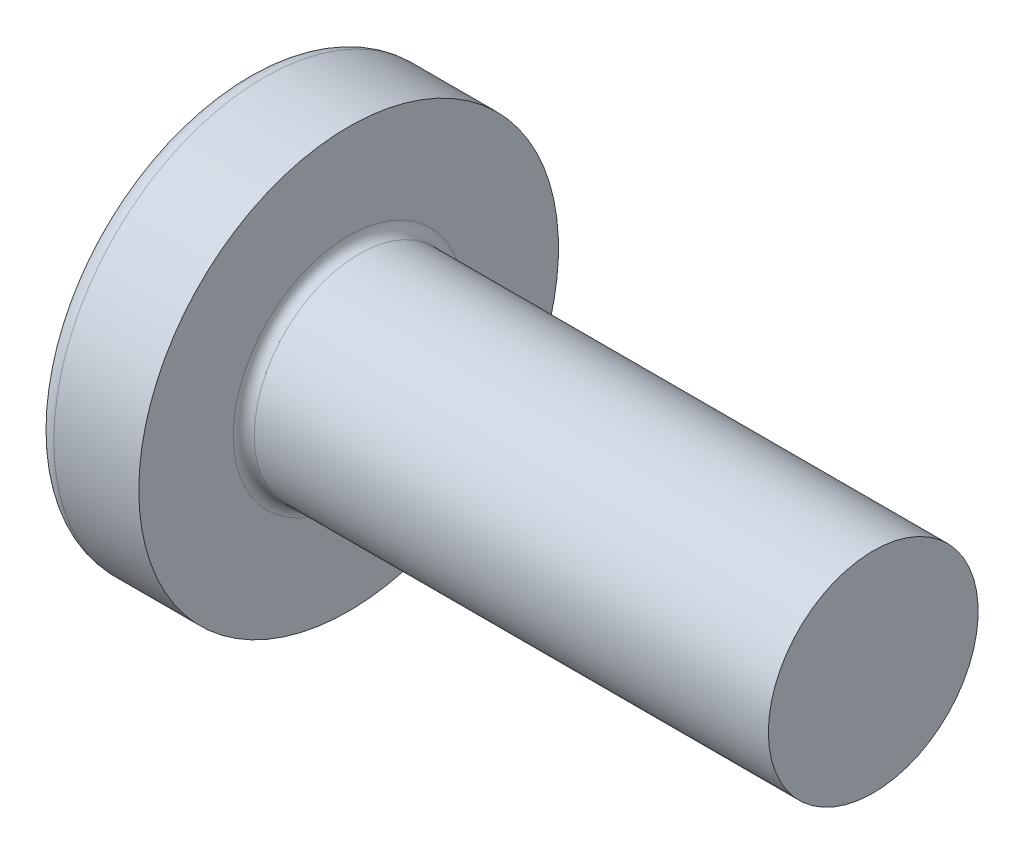
from build123d import *

# Parameters (mm, degrees)
FILLET1_R    = 0.1
SKETCH3_W    = 0.48
SKETCH3_H    = 2.1
SKETCH4_W    = 0.48
SKETCH4_H    = 0.68402847
RECPAT_COUNT = 2
RECPAT_ANGLE = 90


with BuildPart() as part:
    # BodySke → Base-Revolve (revolve)
    with BuildSketch(Plane.XY):
        with BuildLine():
            Line((1.6, 1), (1.6, 2))
            Line((1.6, 2), (0.790020747, 2))
            ThreePointArc((0.790020747, 2), (0.709789294, 1.981130115), (0.646379599, 1.928476821))
            ThreePointArc((0.646379599, 1.928476821), (0.165895084, 1.016959861), (0, 0))
            Line((0, 0), (6.6, 0))
            Line((6.6, 0), (6.6, 1))
            Line((6.6, 1), (1.6, 1))
        make_face()
    revolve(axis=Axis((-25.4, 0, 0), (1, 0, 0)))

    # Fillet1
    fillet1_edges = [part.edges().sort_by_distance(p)[0] for p in [
        (1.6, -1, 0),
    ]]
    fillet(fillet1_edges, radius=FILLET1_R)

    # Sketch3 → Recess section 0
    with BuildSketch(Plane(origin=(0, 0, 0), x_dir=(0, 0, -1), z_dir=(1, 0, 0))):
        Rectangle(SKETCH3_W, SKETCH3_H)
    # Sketch4 → Recess section 1
    with BuildSketch(Plane(origin=(1.42, 0, 0), x_dir=(0, 0, -1), z_dir=(1, 0, 0))):
        Rectangle(SKETCH4_W, SKETCH4_H)
    recess = loft(mode=Mode.SUBTRACT)

    # RecPat: Recess ×2 about axis
    recpat_axis = Axis((0, 0, 0), (1, 0, 0))
    for i in range(1, RECPAT_COUNT):
        add(recess.rotate(recpat_axis, i * RECPAT_ANGLE / (RECPAT_COUNT - 1)), mode=Mode.SUBTRACT)

    # RecCorSke → RecessCore (revolve, cut)
    with BuildSketch(Plane.XY):
        Polygon((0, 0), (0, 0.454796073), (1.42, 0.3555), (1.535508952, 0), align=None)
    revolve(axis=Axis((-3.175, 0, 0), (1, 0, 0)), mode=Mode.SUBTRACT)


solid = part.part
